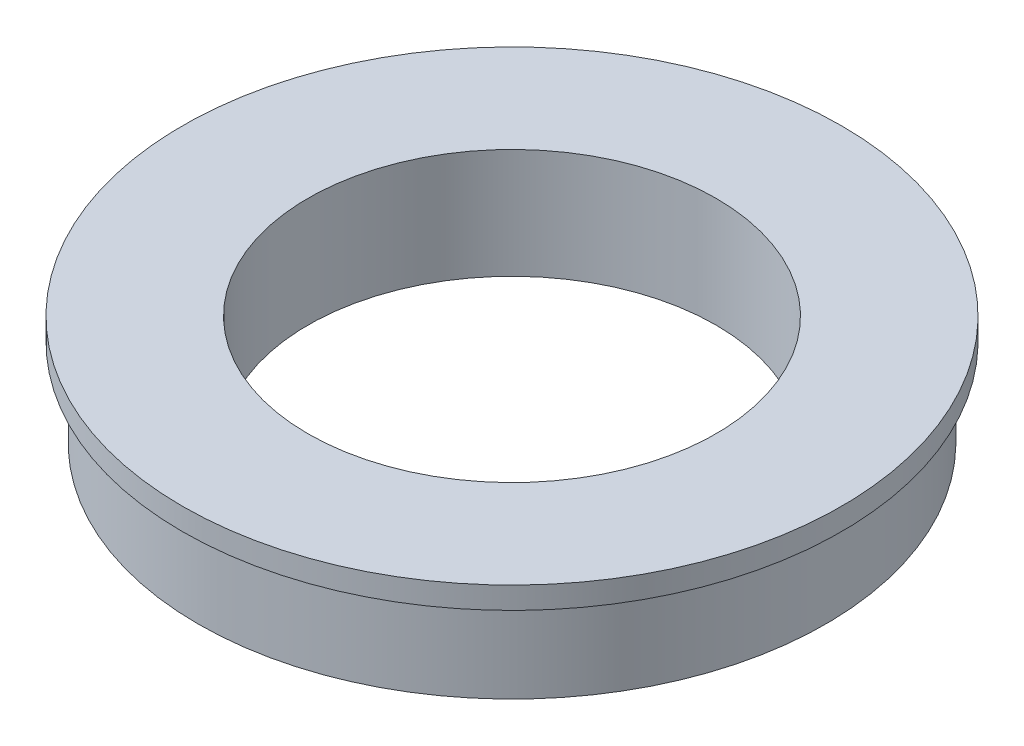
from build123d import *

# Parameters (mm, degrees)
ESQUISSE1_R      = 10
ESQUISSE1_R_2    = 6.5
EXTRUSION1_DEPTH = 3.5
ESQUISSE2_R      = 10.5
ESQUISSE2_R_2    = 10
EXTRUSION2_DEPTH = 0.7
COQUE1_T         = -1


with BuildPart() as part:
    # Esquisse1 → Extrusion1 (new body)
    with BuildSketch(Plane(origin=(0, 0, 0), x_dir=(1, 0, 0), z_dir=(0, 1, 0))):
        with Locations(Location((0, 0, 0), (0, 0, 270))):  # turned: the seam where the file's is
            Circle(ESQUISSE1_R)
        with Locations(Location((0, 0, 0), (0, 0, 270))):  # turned: the seam where the file's is
            Circle(ESQUISSE1_R_2, mode=Mode.SUBTRACT)
    extrude(amount=-EXTRUSION1_DEPTH)

    # Esquisse2 → Extrusion2 (add)
    with BuildSketch(Plane(origin=(0, 0, 0), x_dir=(-1, 0, 0), z_dir=(0, 1, 0))):
        with Locations(Location((0, 0, 0), (0, 0, 90))):  # turned: the seam where the file's is
            Circle(ESQUISSE2_R)
        with Locations(Location((0, 0, 0), (0, 0, 90))):  # turned: the seam where the file's is
            Circle(ESQUISSE2_R_2, mode=Mode.SUBTRACT)
    extrude(amount=-EXTRUSION2_DEPTH)

    # Coque1
    coque1_openings = [part.faces().sort_by_distance(p)[0] for p in [
        (0, -3.5, -9.717157288),
    ]]
    offset(amount=COQUE1_T, openings=coque1_openings, kind=Kind.INTERSECTION)


solid = part.part
